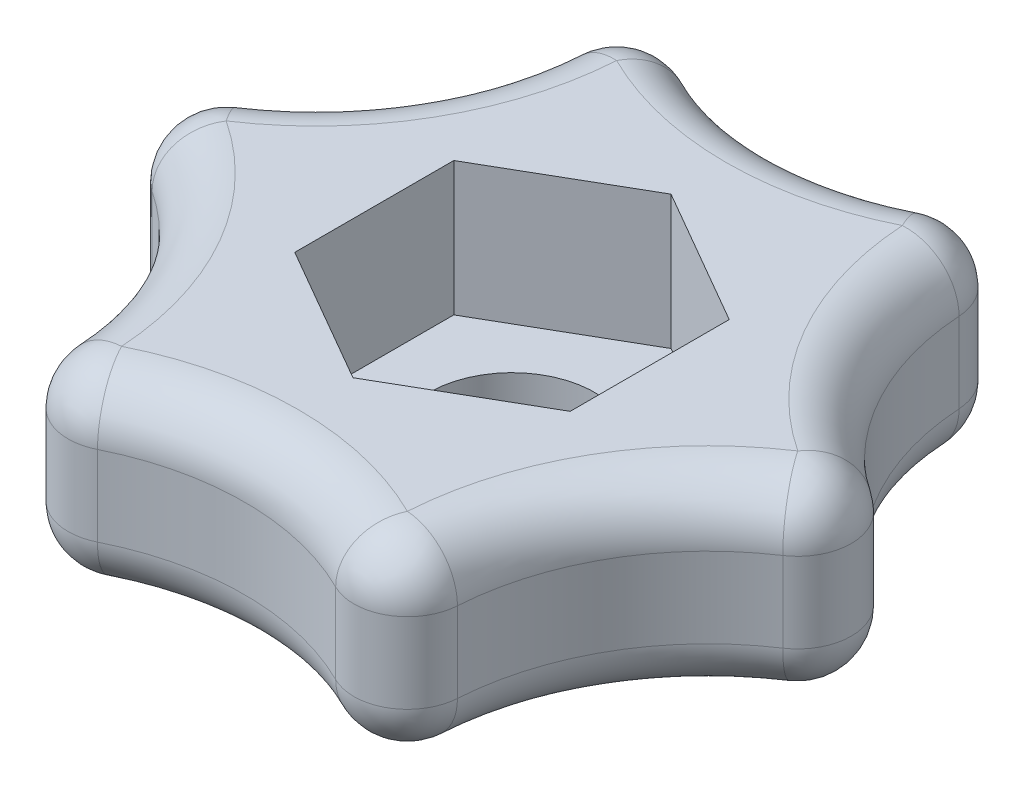
from build123d import *

# Parameters (mm, degrees)
BOSS_EXTRUDE1_DEPTH = 7
CUT_EXTRUDE1_DEPTH  = 5
SKETCH3_R           = 3.1
CUT_EXTRUDE2_DEPTH  = 3
FILLET1_R           = 2


with BuildPart() as part:
    # Sketch1 → Boss-Extrude1 (new body)
    with BuildSketch(Plane(origin=(0, 0, 0), x_dir=(1, 0, 0), z_dir=(0, 1, 0))):
        with BuildLine():
            ThreePointArc((-8.660254038, 15), (0, 10), (8.660254038, 15))
            ThreePointArc((8.660254038, 15), (8.660254038, 5), (17.320508076, 0))
            ThreePointArc((17.320508076, 0), (8.660254038, -5), (8.660254038, -15))
            ThreePointArc((8.660254038, -15), (0, -10), (-8.660254038, -15))
            ThreePointArc((-8.660254038, -15), (-8.660254038, -5), (-17.320508076, 0))
            ThreePointArc((-17.320508076, 0), (-8.660254038, 5), (-8.660254038, 15))
        make_face()
    extrude(amount=BOSS_EXTRUDE1_DEPTH)

    # Sketch2 → Cut-Extrude1 (cut)
    with BuildSketch(Plane(origin=(0, 7, 0), x_dir=(1, 0, 0), z_dir=(0, 1, 0))):
        Polygon((0, -5.946707773), (5.15, -2.973353886), (5.15, 2.973353886), (0, 5.946707773), (-5.15, 2.973353886), (-5.15, -2.973353886), align=None)
    extrude(amount=-CUT_EXTRUDE1_DEPTH, mode=Mode.SUBTRACT)

    # Sketch3 → Cut-Extrude2 (cut, through all)
    with BuildSketch(Plane(origin=(0, 2, 0), x_dir=(1, 0, 0), z_dir=(0, 1, 0))):
        Circle(SKETCH3_R)
    extrude(amount=-CUT_EXTRUDE2_DEPTH, mode=Mode.SUBTRACT)

    # Fillet1
    fillet1_edges = [part.edges().sort_by_distance(p)[0] for p in [
        (8.660254038, 7, -5),
        (-8.660254038, 3.5, 15),
        (-17.320508076, 3.5, 0),
        (-8.660254038, 3.5, -15),
        (8.660254038, 3.5, -15),
        (17.320508076, 3.5, 0),
        (8.660254038, 3.5, 15),
        (0, 7, -10),
        (-8.660254038, 7, -5),
        (-8.660254038, 7, 5),
        (0, 7, 10),
        (-8.660254038, 0, 5),
        (-8.660254038, 0, -5),
        (0, 0, -10),
        (8.660254038, 7, 5),
        (8.660254038, 0, -5),
        (8.660254038, 0, 5),
        (0, 0, 10),
    ]]
    fillet(fillet1_edges, radius=FILLET1_R)


solid = part.part
